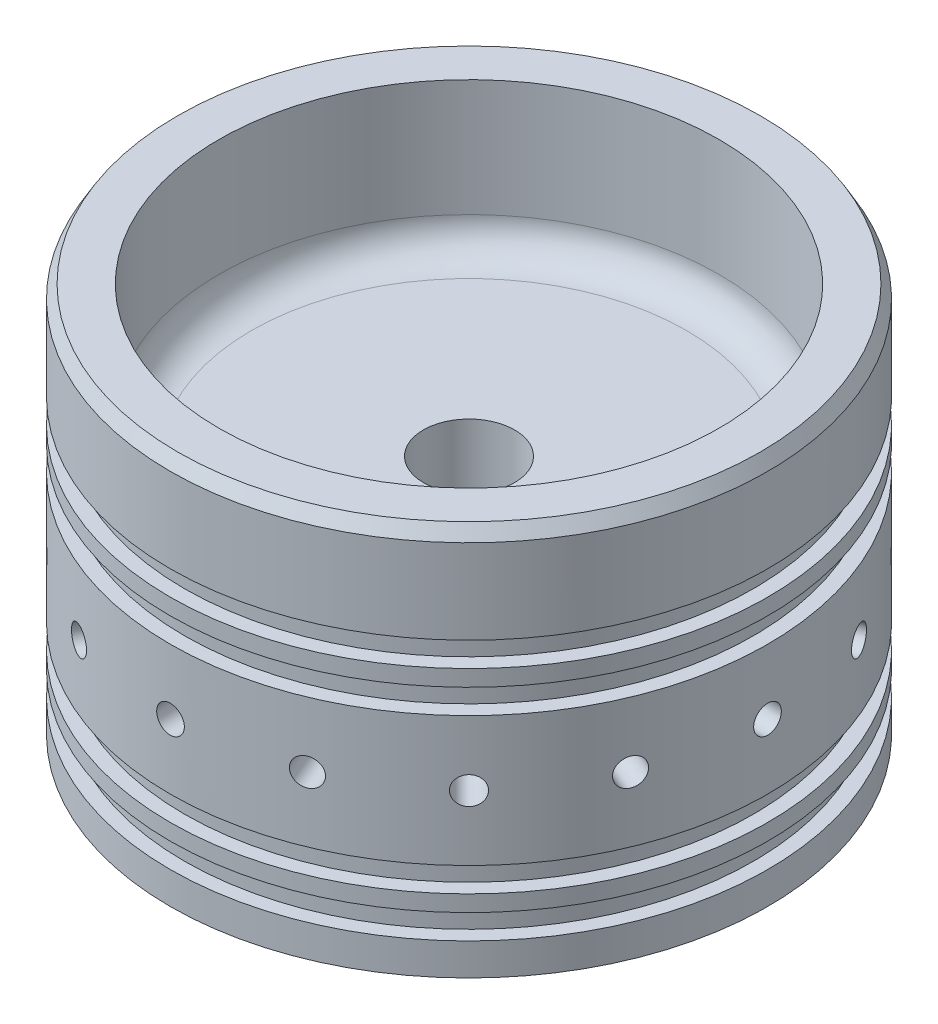
from build123d import *

# Parameters (mm, degrees)
HOLEPATTERN_COUNT             = 16
CHAMFER2_SIZE                 = 2.54
CHAMFER2_SIZE2                = 1.466469684
FILLET1_R                     = 6.35
PIPE_TAP_DRILL_FOR_1_2_TAP1_D = 17.8562


with BuildPart() as part:
    # Sketch1 → Revolve1 (revolve)
    with BuildSketch(Plane.XY):
        Polygon((0, -15.24), (0, 0), (-58.4581, 0), (-58.4581, -12.7), (-55.6641, -12.7), (-55.6641, -17.5006), (-58.4581, -17.5006), (-58.4581, -20.6756), (-55.6641, -20.6756), (-55.6641, -25.4762), (-58.4581, -25.4762), (-58.4581, -31.75), (-48.9331, -31.75), (-48.9331, -15.24), align=None)
        Polygon((-58.4581, 0), (0, 0), (0, 15.3162), (-48.9331, 15.3162), (-48.9331, 44.5262), (-58.4581, 44.5262), (-58.4581, 25.4762), (-55.6387, 25.4762), (-55.6387, 20.6756), (-58.4581, 20.6756), (-58.4581, 17.5006), (-55.6387, 17.5006), (-55.6387, 12.7), (-58.4581, 12.7), align=None)
    revolve(axis=Axis((0, 31.75, 0), (0, -1, 0)))

    # Sketch4 → Tap Drill for 1/4-28 Tap1 (revolve, cut)
    with BuildSketch(Plane(origin=(0, 0, 58.4581), x_dir=(0, -1, 0), z_dir=(1, 0, 0))):
        Polygon((0, 0), (0, 20.675388061), (2.7051, 19.05), (2.7051, 0), align=None)
    tap_drill_for_1_4_28_tap1 = revolve(axis=Axis((0, 0, 64.8081), (0, 0, -1)), mode=Mode.SUBTRACT)

    # HolePattern: Tap Drill for 1/4-28 Tap1 ×16 about axis
    holepattern_axis = Axis((0, -12.7, 0), (0, 1, 0))
    for i in range(1, HOLEPATTERN_COUNT):
        add(tap_drill_for_1_4_28_tap1.rotate(holepattern_axis, i * 360 / HOLEPATTERN_COUNT), mode=Mode.SUBTRACT)

    # Chamfer2
    chamfer2_edges = [part.edges().sort_by_distance(p)[0] for p in [
        (58.4581, 44.5262, 0),
    ]]
    chamfer2_side = [part.faces().sort_by_distance(p)[0] for p in [
        (58.4581, 35.0012, 0),
    ]]
    chamfer(chamfer2_edges, length=CHAMFER2_SIZE, length2=CHAMFER2_SIZE2, reference=chamfer2_side[0])

    # Fillet1
    fillet1_edges = [part.edges().sort_by_distance(p)[0] for p in [
        (48.9331, 15.3162, 0),
        (48.9331, -15.24, 0),
    ]]
    fillet(fillet1_edges, radius=FILLET1_R)

    # Pipe Tap Drill for 1/2 Tap1 (through all)
    with Locations(Plane(origin=(0, 15.3162, 0), x_dir=(1, 0, 0), z_dir=(0, 1, 0))):
        with Locations((0, 0)):
            Hole(PIPE_TAP_DRILL_FOR_1_2_TAP1_D / 2)


solid = part.part
